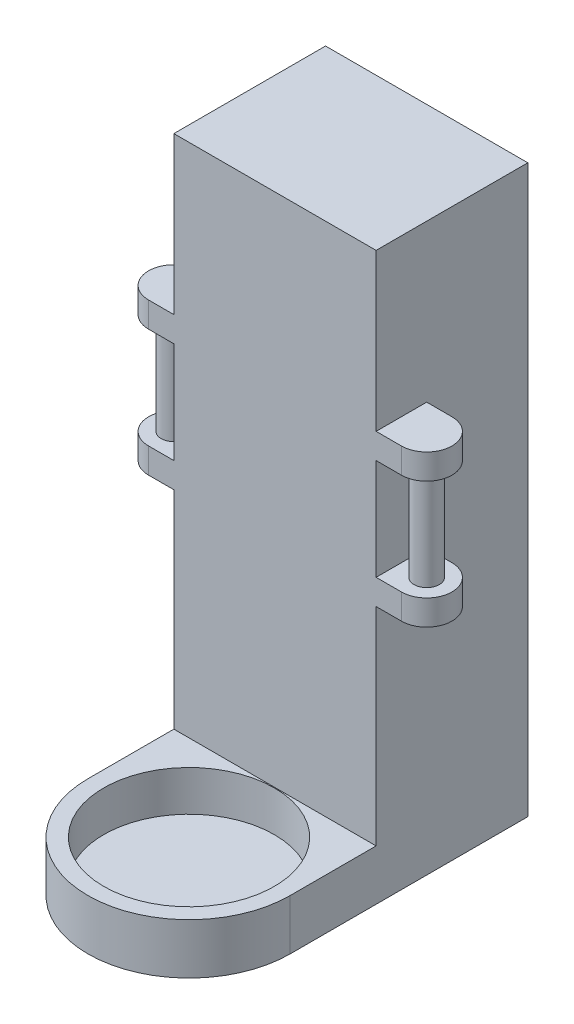
from build123d import *

# Parameters (mm, degrees)
SKETCH1_W            = 50.8
SKETCH1_H            = 142.24
BOSS_EXTRUDE1_DEPTH  = 38.1
SKETCH8_R            = 21.43125
BOSS_EXTRUDE2_DEPTH  = 2.54
SKETCH8_5_R          = 21.43125
BOSS_EXTRUDE9_DEPTH  = 12.7
SKETCH19_W           = 12.7
SKETCH19_H           = 6.35
BOSS_EXTRUDE10_DEPTH = 6.35
BOSS_EXTRUDE11_DEPTH = 6.35
SKETCH23_R           = 3.175
BOSS_EXTRUDE12_DEPTH = 25.4
MIRROR2_COPY_1_DEPTH = 6.35


with BuildPart() as part:
    # Sketch1 → Boss-Extrude1 (new body)
    with BuildSketch(Plane.XY):
        Rectangle(SKETCH1_W, SKETCH1_H)
    extrude(amount=BOSS_EXTRUDE1_DEPTH)



with BuildPart() as body_2:
    # Sketch8 → Boss-Extrude2 (new body)
    with BuildSketch(Plane.XZ.offset(71.12)):
        with BuildLine():
            Line((-25.4, 38.1), (25.4, 38.1))
            Line((25.4, 38.1), (25.4, 59.69))
            ThreePointArc((25.4, 59.69), (0, 85.09), (-25.4, 59.69))
            Line((-25.4, 59.69), (-25.4, 38.1))
        make_face()
        with Locations((0, 59.69)):
            Circle(SKETCH8_R, mode=Mode.SUBTRACT)
        with Locations((0, 59.69)):
            Circle(SKETCH8_R)
    extrude(amount=-BOSS_EXTRUDE2_DEPTH)


with BuildPart() as part_1:
    add(part.part)

    add(body_2.part)  # Boss-Extrude9 merges body 2
    # Sketch8_5 → Boss-Extrude9 (add)
    with BuildSketch(Plane.XZ.offset(71.12)):
        with BuildLine():
            Line((25.4, 38.1), (25.4, 59.69))
            ThreePointArc((25.4, 59.69), (0, 85.09), (-25.4, 59.69))
            Line((-25.4, 59.69), (-25.4, 38.1))
            Line((-25.4, 38.1), (25.4, 38.1))
        make_face()
        with Locations((0, 59.69)):
            Circle(SKETCH8_5_R, mode=Mode.SUBTRACT)
    extrude(amount=-BOSS_EXTRUDE9_DEPTH)

    # Sketch19 → Boss-Extrude10 (add)
    with BuildSketch(Plane.ZY.offset(25.4)):
        with Locations((31.75, 28.575)):
            Rectangle(SKETCH19_W, SKETCH19_H)
        with Locations((31.75, -3.175)):
            Rectangle(SKETCH19_W, SKETCH19_H)
    boss_extrude10 = extrude(amount=BOSS_EXTRUDE10_DEPTH)

    # Sketch20 → Boss-Extrude11 (add)
    with BuildSketch(Plane.XZ.offset(6.35)):
        with BuildLine():
            Line((-31.75, 25.4), (-31.75, 38.1))
            ThreePointArc((-31.75, 38.1), (-38.1, 31.75), (-31.75, 25.4))
        make_face()
    boss_extrude11 = extrude(amount=-BOSS_EXTRUDE11_DEPTH)

    # Mirror1: Boss-Extrude11 across plane
    add(boss_extrude11.mirror(Plane(origin=(0, 12.7, 0), x_dir=(0, 0, 1), z_dir=(0, -1, 0))))

    # Sketch23 → Boss-Extrude12 (add)
    with BuildSketch(Plane.XZ.offset(-25.4)):
        with Locations((-31.75, 31.75)):
            Circle(SKETCH23_R)
    boss_extrude12 = extrude(amount=BOSS_EXTRUDE12_DEPTH)

    # Mirror2: Boss-Extrude12, Boss-Extrude11, Boss-Extrude10 across plane
    add(boss_extrude12.mirror(Plane(origin=(0, 0, 0), x_dir=(0, 0, 1), z_dir=(1, 0, 0))))
    add(boss_extrude11.mirror(Plane(origin=(0, 0, 0), x_dir=(0, 0, 1), z_dir=(1, 0, 0))))
    add(boss_extrude10.mirror(Plane(origin=(0, 0, 0), x_dir=(0, 0, 1), z_dir=(1, 0, 0))))

    # Mirror2 copy 1 sketch → Mirror2 copy 1 (add)
    with BuildSketch(Plane(origin=(0, 31.75, 0), x_dir=(-1, 0, 0), z_dir=(0, 1, 0))):
        with BuildLine():
            Line((-31.75, 25.4), (-31.75, 38.1))
            ThreePointArc((-31.75, 38.1), (-38.1, 31.75), (-31.75, 25.4))
        make_face()
    extrude(amount=-MIRROR2_COPY_1_DEPTH)


solid = part_1.part
